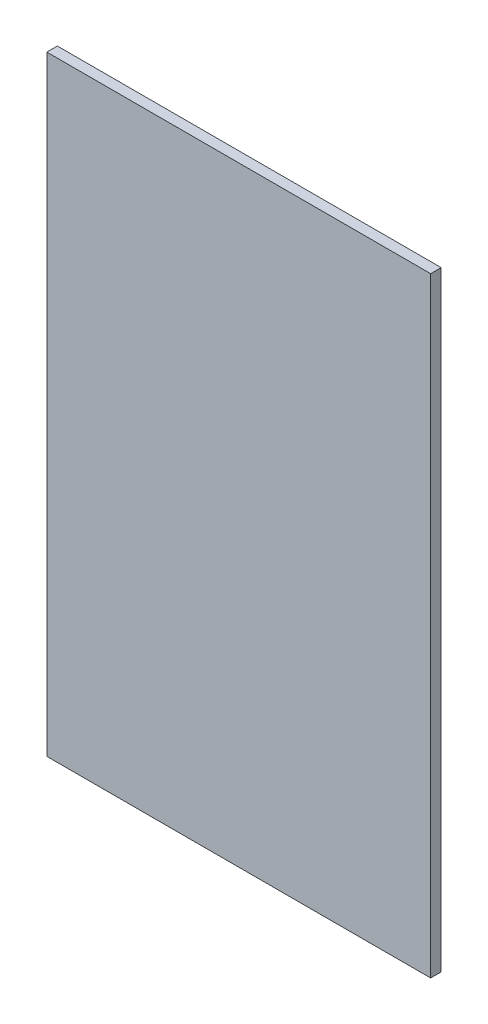
from build123d import *

# Parameters (mm, degrees)
ESQUISSE1_W        = 365
ESQUISSE1_H        = 580
BOSS_EXTRU_1_DEPTH = 10


with BuildPart() as part:
    # Esquisse1 → Boss.-Extru.1 (new body)
    with BuildSketch(Plane.XY):
        with Locations((74.483287049, -245.459393579)):
            Rectangle(ESQUISSE1_W, ESQUISSE1_H)
    extrude(amount=BOSS_EXTRU_1_DEPTH)


solid = part.part
